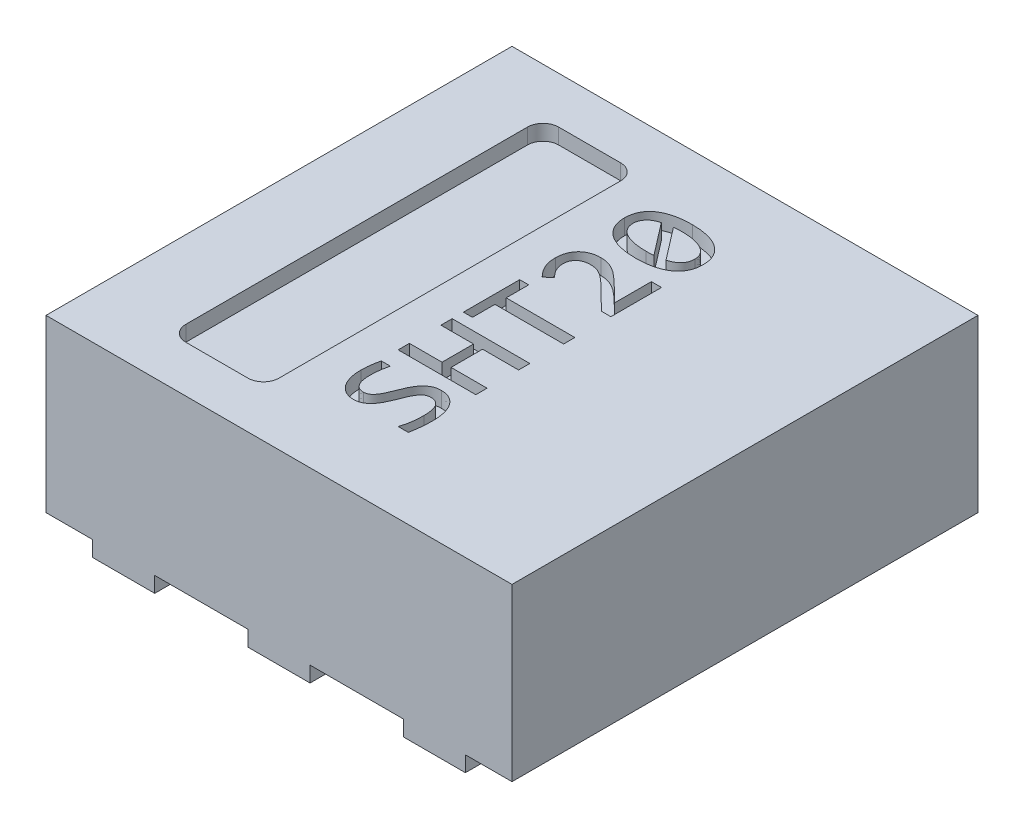
from build123d import *

# Parameters (mm, degrees)
SKETCH_1_W          = 3
SKETCH_1_H          = 3
EXTRUDE_1_DEPTH     = 1.1
CUT_EXTRUDE_1_DEPTH = 0.1
SKETCH_3_W          = 0.4
SKETCH_3_H          = 0.4
EXTRUDE_2_DEPTH     = 0.1
CUT_EXTRUDE_2_DEPTH = 0.1


with BuildPart() as part:
    # Эскиз1 → Бобышка-Вытянуть1 (new body)
    with BuildSketch(Plane(origin=(0, 0, 0), x_dir=(1, 0, 0), z_dir=(0, 1, 0))):
        Rectangle(SKETCH_1_W, SKETCH_1_H)
    extrude(amount=EXTRUDE_1_DEPTH)

    # Эскиз2 → Вырез-Вытянуть1 (cut)
    with BuildSketch(Plane(origin=(0, 1.1, 0), x_dir=(1, 0, 0), z_dir=(0, 1, 0))):
        with BuildLine():
            Line((-0.9, 1.2), (-0.5, 1.2))
            ThreePointArc((-0.5, 1.2), (-0.429289322, 1.170710678), (-0.4, 1.1))
            Line((-0.4, 1.1), (-0.4, -1.1))
            ThreePointArc((-0.4, -1.1), (-0.429289322, -1.170710678), (-0.5, -1.2))
            Line((-0.5, -1.2), (-0.9, -1.2))
            ThreePointArc((-0.9, -1.2), (-0.970710678, -1.170710678), (-1, -1.1))
            Line((-1, -1.1), (-1, 1.1))
            ThreePointArc((-1, 1.1), (-0.970710678, 1.170710678), (-0.9, 1.2))
        make_face()
    extrude(amount=-CUT_EXTRUDE_1_DEPTH, mode=Mode.SUBTRACT)

    # Эскиз3 → Бобышка-Вытянуть2 (add)
    with BuildSketch(Plane.XZ):
        Polygon((1.2, -0.75), (-1.2, -0.75), (-1.2, 0.35), (-0.8, 0.75), (1.2, 0.75), align=None)
        with Locations((1, -1.3)):
            Rectangle(SKETCH_3_W, SKETCH_3_H)
        with Locations((0, -1.3)):
            Rectangle(SKETCH_3_W, SKETCH_3_H)
        with Locations((-1, -1.3)):
            Rectangle(SKETCH_3_W, SKETCH_3_H)
        with Locations((1, 1.3)):
            Rectangle(SKETCH_3_W, SKETCH_3_H)
        with Locations((0, 1.3)):
            Rectangle(SKETCH_3_W, SKETCH_3_H)
        with Locations((-1, 1.3)):
            Rectangle(SKETCH_3_W, SKETCH_3_H)
    extrude(amount=EXTRUDE_2_DEPTH)

    # Эскиз4 → Вырез-Вытянуть2 (cut)
    with BuildSketch(Plane(origin=(0, 1.1, 0), x_dir=(1, 0, 0), z_dir=(0, 1, 0))):
        with BuildLine():
            add(Edge.make_bspline(
                [(0.190506672, -0.645766867), (0.196291492, -0.645933457), (0.20755118, -0.646257709), (0.223893074, -0.648989474), (0.239052887, -0.653672633), (0.253140322, -0.660057197), (0.266025063, -0.668126326), (0.277864823, -0.677647531), (0.288511242, -0.688642293), (0.297922262, -0.701146172), (0.306372605, -0.714860059), (0.313446819, -0.730071994), (0.31956784, -0.746495785), (0.324517643, -0.764190834), (0.328295084, -0.783011345), (0.33117149, -0.802809666), (0.332705802, -0.823580535), (0.332938038, -0.837718111), (0.333056491, -0.844929005)],
                knots=[0, 0, 0, 0, 1.7347e-05, 3.3765e-05, 4.9523e-05, 6.4825e-05, 8.0031e-05, 9.5009e-05, 0.000110302, 0.000125814, 0.000141874, 0.000158536, 0.000176056, 0.000194408, 0.000213593, 0.000233609, 0.000254389, 0.000276023, 0.000276023, 0.000276023, 0.000276023], degree=3))
            add(Edge.make_bspline(
                [(0.333056491, -0.844929005), (0.332998648, -0.851573327), (0.332883221, -0.864831989), (0.331727024, -0.884528981), (0.330473184, -0.903829605), (0.328581794, -0.922388042), (0.326658131, -0.94011778), (0.324082097, -0.956700635), (0.32161067, -0.972059482), (0.319544225, -0.981749061), (0.318563737, -0.986346578)],
                knots=[0, 0, 0, 0, 1.993e-05, 3.9771e-05, 5.918e-05, 7.795e-05, 9.573e-05, 0.000112671, 0.000128288, 0.000142389, 0.000142389, 0.000142389, 0.000142389], degree=3))
            Line((0.318563737, -0.986346578), (0.253346346, -0.986346578))
            add(Edge.make_bspline(
                [(0.253346346, -0.986346578), (0.25503366, -0.981421988), (0.258481268, -0.971359811), (0.262524998, -0.955576348), (0.266322687, -0.939020013), (0.269495419, -0.921533481), (0.271992514, -0.902946391), (0.273748691, -0.883187828), (0.27493796, -0.862191417), (0.275035389, -0.847799112), (0.275085477, -0.84040002)],
                knots=[0, 0, 0, 0, 1.5611e-05, 3.1897e-05, 4.8845e-05, 6.6568e-05, 8.5191e-05, 0.000105087, 0.000126065, 0.000148259, 0.000148259, 0.000148259, 0.000148259], degree=3))
            add(Edge.make_bspline(
                [(0.275085477, -0.84040002), (0.275031059, -0.835113724), (0.274926389, -0.824945766), (0.273832092, -0.810294257), (0.272405406, -0.796840067), (0.269927368, -0.784612186), (0.267075136, -0.773487869), (0.263445537, -0.76343295), (0.259126217, -0.754463015), (0.254283683, -0.746422537), (0.248689894, -0.739529221), (0.242656931, -0.733494189), (0.235916222, -0.728601157), (0.228604834, -0.724760995), (0.220819494, -0.721761086), (0.212476972, -0.719773992), (0.203604597, -0.71849462), (0.197493494, -0.718320184), (0.19435631, -0.718230636)],
                knots=[0, 0, 0, 0, 1.5855e-05, 3.0497e-05, 4.4063e-05, 5.6409e-05, 6.7889e-05, 7.8491e-05, 8.8417e-05, 9.7719e-05, 0.000106578, 0.000114985, 0.000123251, 0.000131456, 0.000139699, 0.000148212, 0.000157131, 0.00016654, 0.00016654, 0.00016654, 0.00016654], degree=3))
            add(Edge.make_bspline(
                [(0.19435631, -0.718230636), (0.191096846, -0.718343064), (0.184728538, -0.718562724), (0.175592246, -0.720806407), (0.167119782, -0.724314391), (0.159563589, -0.729457264), (0.152463983, -0.735501066), (0.145958178, -0.742601016), (0.139668436, -0.750438917), (0.131752132, -0.762328705), (0.122494968, -0.779002331), (0.112991401, -0.801080587), (0.103877319, -0.824678698), (0.094071768, -0.848757066), (0.083806669, -0.872927174), (0.072639906, -0.896471069), (0.060320198, -0.918833584), (0.047650336, -0.935354783), (0.036578133, -0.947163355), (0.02758022, -0.955056226), (0.017762574, -0.96191825), (0.007392035, -0.968146492), (-0.003964964, -0.973084763), (-0.016266722, -0.97653706), (-0.029557991, -0.978784672), (-0.038763513, -0.978992579), (-0.043528654, -0.979100201)],
                knots=[0, 0, 0, 0, 9.761e-06, 1.9071e-05, 2.8051e-05, 3.7126e-05, 4.6362e-05, 5.5974e-05, 6.5965e-05, 7.6485e-05, 9.8788e-05, 0.000123068, 0.00014853, 0.000174686, 0.00020106, 0.000227293, 0.000252853, 0.000277491, 0.000289505, 0.000301381, 0.000313319, 0.000325398, 0.000337618, 0.000350341, 0.00036365, 0.000377932, 0.000377932, 0.000377932, 0.000377932], degree=3))
            add(Edge.make_bspline(
                [(-0.043528654, -0.979100201), (-0.047801662, -0.978970292), (-0.056358176, -0.978710155), (-0.069143663, -0.976561324), (-0.081817294, -0.973181604), (-0.094333665, -0.968424094), (-0.106400444, -0.962190167), (-0.117976783, -0.954611517), (-0.128624141, -0.945253826), (-0.138781786, -0.934644748), (-0.147983004, -0.922274593), (-0.15622054, -0.9083319), (-0.163445654, -0.892743026), (-0.169963097, -0.875659162), (-0.175149041, -0.85679107), (-0.178860956, -0.836221242), (-0.180956789, -0.813948923), (-0.181272773, -0.798549037), (-0.181436263, -0.790581179)],
                knots=[0, 0, 0, 0, 1.2812e-05, 2.5656e-05, 3.8784e-05, 5.2116e-05, 6.5738e-05, 7.9461e-05, 9.3511e-05, 0.000108167, 0.000123453, 0.000139647, 0.000156666, 0.00017494, 0.000194444, 0.000215275, 0.000237571, 0.000261475, 0.000261475, 0.000261475, 0.000261475], degree=3))
            add(Edge.make_bspline(
                [(-0.181436263, -0.790581179), (-0.18134857, -0.786126869), (-0.181166383, -0.776872789), (-0.180374349, -0.762595553), (-0.179013786, -0.747721147), (-0.177179421, -0.732589437), (-0.175059139, -0.71748423), (-0.172566537, -0.702654474), (-0.169904449, -0.68841863), (-0.167907502, -0.679201698), (-0.166943509, -0.674752375)],
                knots=[0, 0, 0, 0, 1.3365e-05, 2.7766e-05, 4.2886e-05, 5.8166e-05, 7.349e-05, 8.8642e-05, 0.000103276, 0.000116933, 0.000116933, 0.000116933, 0.000116933], degree=3))
            Line((-0.166943509, -0.674752375), (-0.108972494, -0.674752375))
            add(Edge.make_bspline(
                [(-0.108972494, -0.674752375), (-0.111152689, -0.684658093), (-0.115492688, -0.704376892), (-0.12009266, -0.734006771), (-0.122909142, -0.763163549), (-0.123282073, -0.782385344), (-0.123465248, -0.79182665)],
                knots=[0, 0, 0, 0, 3.0422e-05, 6.056e-05, 8.9898e-05, 0.000118219, 0.000118219, 0.000118219, 0.000118219], degree=3))
            add(Edge.make_bspline(
                [(-0.123465248, -0.79182665), (-0.123392542, -0.79658327), (-0.123251608, -0.805803463), (-0.122385106, -0.819151769), (-0.120798379, -0.831511289), (-0.118652336, -0.842894581), (-0.115996576, -0.853333103), (-0.112622548, -0.862794729), (-0.108504102, -0.871227333), (-0.103876768, -0.878772797), (-0.098638385, -0.885320338), (-0.093077165, -0.891076166), (-0.087029943, -0.895881655), (-0.080497798, -0.899760705), (-0.073567578, -0.902796371), (-0.066268263, -0.905153938), (-0.058475948, -0.906350493), (-0.05315614, -0.906539676), (-0.050435357, -0.906636433)],
                knots=[0, 0, 0, 0, 1.427e-05, 2.7662e-05, 4.0104e-05, 5.1629e-05, 6.2395e-05, 7.2387e-05, 8.1705e-05, 9.0502e-05, 9.8884e-05, 0.00010681, 0.000114467, 0.000121982, 0.000129535, 0.000137127, 0.000144926, 0.000153091, 0.000153091, 0.000153091, 0.000153091], degree=3))
            add(Edge.make_bspline(
                [(-0.050435357, -0.906636433), (-0.047175778, -0.906524768), (-0.040807246, -0.906306599), (-0.031638586, -0.904043866), (-0.023149523, -0.900562109), (-0.015439942, -0.895517847), (-0.008399772, -0.889358222), (-0.001651622, -0.882391449), (0.00469448, -0.874535987), (0.01280075, -0.862661446), (0.022087686, -0.845909498), (0.03158257, -0.823761921), (0.040865253, -0.800214709), (0.050640483, -0.776109783), (0.06088313, -0.751911991), (0.070392355, -0.73218363), (0.07855915, -0.716873854), (0.085404979, -0.706144883), (0.092624812, -0.695957172), (0.100602687, -0.686591621), (0.109034888, -0.677795046), (0.118300976, -0.669979495), (0.128120737, -0.662900327), (0.138777492, -0.656862946), (0.150234411, -0.651743344), (0.162800481, -0.64834273), (0.176309386, -0.646079689), (0.185665684, -0.645873533), (0.190506672, -0.645766867)],
                knots=[0, 0, 0, 0, 9.761e-06, 1.9071e-05, 2.8155e-05, 3.7169e-05, 4.6564e-05, 5.6173e-05, 6.6234e-05, 7.6818e-05, 9.9275e-05, 0.000123555, 0.000149059, 0.000175215, 0.000201589, 0.000227871, 0.000240893, 0.000253615, 0.000266027, 0.00027832, 0.000290491, 0.000302538, 0.000314634, 0.000326754, 0.000339228, 0.000352168, 0.0003657, 0.000380209, 0.000380209, 0.000380209, 0.000380209], degree=3))
        make_face()
        Polygon((0.325810114, -0.210984259), (0.325810114, -0.283448027), (0.093926056, -0.283448027), (0.093926056, -0.486346578), (0.325810114, -0.486346578), (0.325810114, -0.558810346), (-0.174189886, -0.558810346), (-0.174189886, -0.486346578), (0.035955042, -0.486346578), (0.035955042, -0.283448027), (-0.174189886, -0.283448027), (-0.174189886, -0.210984259), align=None)
        Polygon((-0.116218871, 0.22379835), (-0.116218871, 0.078870814), (0.325810114, 0.078870814), (0.325810114, 0.006407046), (-0.116218871, 0.006407046), (-0.116218871, -0.138520491), (-0.174189886, -0.138520491), (-0.174189886, 0.22379835), align=None)
        with BuildLine():
            Line((0.325810114, 0.636841828), (0.325810114, 0.310754872))
            Line((0.325810114, 0.310754872), (0.264329136, 0.310754872))
            Line((0.264329136, 0.310754872), (0.137064643, 0.436660669))
            add(Edge.make_bspline(
                [(0.137064643, 0.436660669), (0.132048273, 0.441570121), (0.122434464, 0.450979025), (0.108587052, 0.464432663), (0.09549962, 0.476178409), (0.083458948, 0.486679149), (0.072199311, 0.49598389), (0.061409762, 0.503982309), (0.051257472, 0.511103316), (0.041442476, 0.516971297), (0.032121498, 0.522069564), (0.0230103, 0.526115165), (0.014211987, 0.529516946), (0.002529255, 0.53245972), (-0.012476403, 0.534945987), (-0.024683584, 0.535240902), (-0.030960719, 0.535392553)],
                knots=[0, 0, 0, 0, 2.1058e-05, 4.0357e-05, 5.7912e-05, 7.3804e-05, 8.8287e-05, 0.000101716, 0.00011409, 0.000125469, 0.000136005, 0.000145938, 0.00015536, 0.000164258, 0.000182035, 0.000200852, 0.000200852, 0.000200852, 0.000200852], degree=3))
            add(Edge.make_bspline(
                [(-0.030960719, 0.535392553), (-0.03701848, 0.535154055), (-0.048980379, 0.534683108), (-0.063531801, 0.531537569), (-0.074547973, 0.528011307), (-0.082143194, 0.524404618), (-0.089336952, 0.520339597), (-0.096036694, 0.515622655), (-0.102054025, 0.510095898), (-0.107629402, 0.504001059), (-0.11215838, 0.49685607), (-0.116364733, 0.489186897), (-0.119461288, 0.480578093), (-0.121895105, 0.47127184), (-0.123216732, 0.461117052), (-0.123380565, 0.454100721), (-0.123465248, 0.450474075)],
                knots=[0, 0, 0, 0, 1.8159e-05, 3.5857e-05, 4.445e-05, 5.2809e-05, 6.1024e-05, 6.9224e-05, 7.7321e-05, 8.5501e-05, 9.3917e-05, 0.000102629, 0.000111693, 0.000121277, 0.000131445, 0.000142324, 0.000142324, 0.000142324, 0.000142324], degree=3))
            add(Edge.make_bspline(
                [(-0.123465248, 0.450474075), (-0.123284107, 0.44540627), (-0.122926147, 0.435391628), (-0.120297004, 0.420722925), (-0.115829036, 0.406774419), (-0.109656958, 0.393584072), (-0.101947236, 0.381117115), (-0.093224305, 0.36916678), (-0.083580126, 0.357584065), (-0.076387486, 0.350477011), (-0.07274061, 0.346873531)],
                knots=[0, 0, 0, 0, 1.5199e-05, 3.0035e-05, 4.4537e-05, 5.9025e-05, 7.3608e-05, 8.8442e-05, 0.000103389, 0.000118761, 0.000118761, 0.000118761, 0.000118761], degree=3))
            Line((-0.07274061, 0.346873531), (-0.116332096, 0.310754872))
            add(Edge.make_bspline(
                [(-0.116332096, 0.310754872), (-0.121109258, 0.315496522), (-0.130633781, 0.324950243), (-0.143158482, 0.340698468), (-0.154299096, 0.357397819), (-0.164058373, 0.375149794), (-0.171984712, 0.394264173), (-0.177479746, 0.414932625), (-0.180804313, 0.43704328), (-0.181221788, 0.452273689), (-0.181436263, 0.460098169)],
                knots=[0, 0, 0, 0, 2.0178e-05, 4.023e-05, 6.0234e-05, 8.0349e-05, 0.000100912, 0.000122144, 0.000144353, 0.000167818, 0.000167818, 0.000167818, 0.000167818], degree=3))
            add(Edge.make_bspline(
                [(-0.181436263, 0.460098169), (-0.181354737, 0.46546441), (-0.181195142, 0.475969467), (-0.1791438, 0.49133441), (-0.176143021, 0.506009061), (-0.171886576, 0.51995704), (-0.166235717, 0.533006938), (-0.159786631, 0.54528801), (-0.151927174, 0.556490616), (-0.143119572, 0.566792811), (-0.133240268, 0.576184779), (-0.12216011, 0.584270103), (-0.110236756, 0.591554013), (-0.097104692, 0.597352986), (-0.083121811, 0.602187404), (-0.068171092, 0.605357383), (-0.05246027, 0.607504813), (-0.041686995, 0.607737263), (-0.036169052, 0.607856321)],
                knots=[0, 0, 0, 0, 1.6088e-05, 3.1494e-05, 4.6416e-05, 6.0992e-05, 7.5146e-05, 8.9026e-05, 0.000102532, 0.000116102, 0.000129638, 0.000143316, 0.000157181, 0.000171471, 0.000186294, 0.000201485, 0.000217243, 0.000233788, 0.000233788, 0.000233788, 0.000233788], degree=3))
            add(Edge.make_bspline(
                [(-0.036169052, 0.607856321), (-0.031486339, 0.607768086), (-0.022251734, 0.607594081), (-0.008689379, 0.606258983), (0.004320696, 0.603840308), (0.016882838, 0.600535208), (0.029192838, 0.596274505), (0.041451312, 0.591220185), (0.053573556, 0.58501721), (0.065767751, 0.577985275), (0.077967639, 0.569853045), (0.090503758, 0.560967357), (0.103001295, 0.550758607), (0.115979566, 0.539810944), (0.12918276, 0.527664947), (0.14319667, 0.514813498), (0.157641509, 0.500716574), (0.167455454, 0.490941758), (0.172503955, 0.485913386)],
                knots=[0, 0, 0, 0, 1.4047e-05, 2.7702e-05, 4.0827e-05, 5.3707e-05, 6.6633e-05, 7.988e-05, 9.3451e-05, 0.000107453, 0.000122087, 0.00013742, 0.000153529, 0.000170477, 0.000188353, 0.000207341, 0.000227519, 0.000248896, 0.000248896, 0.000248896, 0.000248896], degree=3))
            Line((0.172503955, 0.485913386), (0.260592723, 0.397711393))
            Line((0.260592723, 0.397711393), (0.260592723, 0.636841828))
            Line((0.260592723, 0.636841828), (0.325810114, 0.636841828))
        make_face()
        with BuildLine():
            add(Edge.make_bspline(
                [(0.076036564, 1.08611719), (0.085401821, 1.086013896), (0.103746126, 1.085811567), (0.130579673, 1.083434075), (0.156191183, 1.079881938), (0.180485482, 1.074811288), (0.20337435, 1.068369172), (0.224564319, 1.06013958), (0.244126089, 1.050553188), (0.262002621, 1.03941123), (0.278138205, 1.026893027), (0.292362457, 1.012794431), (0.304631872, 0.997256812), (0.314895467, 0.980219235), (0.32319079, 0.961754767), (0.3288536, 0.941648191), (0.332496839, 0.920073604), (0.332866284, 0.905162071), (0.333056491, 0.897484944)],
                knots=[0, 0, 0, 0, 2.8088e-05, 5.5018e-05, 8.0749e-05, 0.00010562, 0.000129416, 0.000151998, 0.000173721, 0.000194676, 0.000215083, 0.000234859, 0.000254611, 0.00027432, 0.000294393, 0.00031514, 0.000336825, 0.000359838, 0.000359838, 0.000359838, 0.000359838], degree=3))
            add(Edge.make_bspline(
                [(0.333056491, 0.897484944), (0.332895386, 0.890832366), (0.332578062, 0.877728947), (0.329689074, 0.858552282), (0.324927139, 0.840286619), (0.318261298, 0.823005369), (0.309578398, 0.806818068), (0.299005574, 0.791700893), (0.286180643, 0.777952298), (0.271331418, 0.765455674), (0.254484377, 0.754159341), (0.235348081, 0.744453353), (0.214153242, 0.736021484), (0.190815558, 0.728829354), (0.165262985, 0.723414424), (0.137516505, 0.719305529), (0.107515078, 0.716983081), (0.086759079, 0.716698821), (0.076036564, 0.716551973)],
                knots=[0, 0, 0, 0, 1.9948e-05, 3.9291e-05, 5.8021e-05, 7.6482e-05, 9.4718e-05, 0.000113001, 0.000131669, 0.00015095, 0.000171111, 0.000192379, 0.000215192, 0.000239474, 0.000265547, 0.000293473, 0.000323571, 0.000355737, 0.000355737, 0.000355737, 0.000355737], degree=3))
            add(Edge.make_bspline(
                [(0.076036564, 0.716551973), (0.066673173, 0.71672094), (0.048298949, 0.717052512), (0.021364087, 0.719155768), (-0.00434448, 0.722924323), (-0.028726043, 0.728051971), (-0.051655146, 0.734680712), (-0.072916609, 0.742881954), (-0.092583886, 0.752319409), (-0.110515566, 0.763327603), (-0.126522285, 0.775933063), (-0.140743304, 0.789984098), (-0.153044075, 0.805543988), (-0.163273806, 0.822681836), (-0.171550493, 0.841224993), (-0.177221754, 0.861324253), (-0.1808721, 0.882783721), (-0.181244812, 0.89758254), (-0.181436263, 0.905184219)],
                knots=[0, 0, 0, 0, 2.8091e-05, 5.5124e-05, 8.0984e-05, 0.000105989, 0.000129816, 0.000152504, 0.000174279, 0.000195175, 0.000215493, 0.000235268, 0.00025502, 0.000274826, 0.000295002, 0.00031575, 0.000337323, 0.00036011, 0.00036011, 0.00036011, 0.00036011], degree=3))
            add(Edge.make_bspline(
                [(-0.181436263, 0.905184219), (-0.181273423, 0.911836299), (-0.180952682, 0.924938737), (-0.178093868, 0.944086315), (-0.17326051, 0.962278911), (-0.166744736, 0.979590876), (-0.15814215, 0.995848642), (-0.147336523, 1.010868116), (-0.134453369, 1.024568938), (-0.119591025, 1.037147171), (-0.102596624, 1.048364132), (-0.083473378, 1.058244161), (-0.06216306, 1.066503029), (-0.038845306, 1.07370449), (-0.013283034, 1.079305504), (0.014485622, 1.083334284), (0.044518865, 1.085698914), (0.065275856, 1.085974384), (0.076036564, 1.08611719)],
                knots=[0, 0, 0, 0, 1.9948e-05, 3.9291e-05, 5.7912e-05, 7.6332e-05, 9.4668e-05, 0.000112924, 0.000131669, 0.000150951, 0.000171205, 0.000192626, 0.000215397, 0.000239679, 0.000265776, 0.000293814, 0.0003238, 0.000356079, 0.000356079, 0.000356079, 0.000356079], degree=3))
        make_face()
        with BuildLine():
            add(Edge.make_bspline(
                [(0.079886201, 1.013653422), (0.075544045, 1.013626604), (0.066852353, 1.013572922), (0.053955239, 1.012622791), (0.041227233, 1.0117996), (0.03285858, 1.010995233), (0.028708665, 1.010596357)],
                knots=[0, 0, 0, 0, 1.3023e-05, 2.6068e-05, 3.8781e-05, 5.1287e-05, 5.1287e-05, 5.1287e-05, 5.1287e-05], degree=3))
            Line((0.028708665, 1.010596357), (0.188128955, 0.803168821))
            add(Edge.make_bspline(
                [(0.188128955, 0.803168821), (0.194288622, 0.805200044), (0.206305198, 0.809162652), (0.223170883, 0.816986514), (0.238275648, 0.826366744), (0.250986303, 0.837891255), (0.261524384, 0.850957242), (0.267847917, 0.863439202), (0.271643287, 0.874103052), (0.273696581, 0.8827534), (0.274774469, 0.891947425), (0.274980375, 0.898237257), (0.275085477, 0.901447806)],
                knots=[0, 0, 0, 0, 1.9445e-05, 3.7934e-05, 5.5649e-05, 7.2565e-05, 8.9169e-05, 0.000105728, 0.000114251, 0.000123094, 0.000132335, 0.00014197, 0.00014197, 0.00014197, 0.00014197], degree=3))
            add(Edge.make_bspline(
                [(0.275085477, 0.901447806), (0.274942409, 0.905612598), (0.274660355, 0.913823419), (0.272142393, 0.925796095), (0.268381219, 0.937263412), (0.26265947, 0.947954394), (0.255699626, 0.958088583), (0.247020317, 0.967310178), (0.237002332, 0.975880157), (0.225362381, 0.983543483), (0.212267766, 0.990442137), (0.197696988, 0.996579089), (0.181582791, 1.001739514), (0.164005428, 1.005959956), (0.145048964, 1.009526447), (0.124624225, 1.011946417), (0.10274256, 1.013441183), (0.087663543, 1.013581203), (0.079886201, 1.013653422)],
                knots=[0, 0, 0, 0, 1.248e-05, 2.4604e-05, 3.6563e-05, 4.8565e-05, 6.0846e-05, 7.3345e-05, 8.6437e-05, 0.000100317, 0.000115056, 0.000130786, 0.000147686, 0.000165756, 0.000184987, 0.000205519, 0.000227421, 0.00025075, 0.00025075, 0.00025075, 0.00025075], degree=3))
        make_face(mode=Mode.SUBTRACT)
        with BuildLine():
            add(Edge.make_bspline(
                [(0.075243991, 0.789015741), (0.079282358, 0.789011032), (0.087359267, 0.789001615), (0.099401554, 0.789071826), (0.111265366, 0.789471279), (0.11906413, 0.79015189), (0.122911564, 0.790487662)],
                knots=[0, 0, 0, 0, 1.2115e-05, 2.4231e-05, 3.6128e-05, 4.7712e-05, 4.7712e-05, 4.7712e-05, 4.7712e-05], degree=3))
            Line((0.122911564, 0.790487662), (-0.036508726, 0.998028422))
            add(Edge.make_bspline(
                [(-0.036508726, 0.998028422), (-0.042714255, 0.996057043), (-0.054814511, 0.992213018), (-0.071575162, 0.984239285), (-0.086568621, 0.974846707), (-0.099340303, 0.963628393), (-0.109781303, 0.950610492), (-0.116222953, 0.938346281), (-0.120001945, 0.927807036), (-0.122080663, 0.919353402), (-0.123148483, 0.910419868), (-0.123358591, 0.904318552), (-0.123465248, 0.901221357)],
                knots=[0, 0, 0, 0, 1.9514e-05, 3.8051e-05, 5.5515e-05, 7.244e-05, 8.8797e-05, 0.000105308, 0.000113724, 0.000122347, 0.000131363, 0.000140658, 0.000140658, 0.000140658, 0.000140658], degree=3))
            add(Edge.make_bspline(
                [(-0.123465248, 0.901221357), (-0.123317161, 0.897058396), (-0.12302521, 0.888851185), (-0.120584199, 0.876875082), (-0.116554581, 0.865495111), (-0.110980853, 0.854701173), (-0.103840185, 0.844541128), (-0.094899626, 0.835364124), (-0.084735247, 0.826662503), (-0.072798424, 0.818997706), (-0.059419799, 0.812091819), (-0.04448968, 0.806136378), (-0.028134959, 0.800959906), (-0.010340968, 0.796512304), (0.009004745, 0.793189756), (0.029787624, 0.790715398), (0.052048991, 0.789231291), (0.067353696, 0.789089065), (0.075243991, 0.789015741)],
                knots=[0, 0, 0, 0, 1.248e-05, 2.4604e-05, 3.6493e-05, 4.8596e-05, 6.0942e-05, 7.3596e-05, 8.6933e-05, 0.000101002, 0.000116043, 0.000132043, 0.000149159, 0.000167475, 0.000187021, 0.000208003, 0.000230244, 0.000253912, 0.000253912, 0.000253912, 0.000253912], degree=3))
        make_face(mode=Mode.SUBTRACT)
    extrude(amount=-CUT_EXTRUDE_2_DEPTH, mode=Mode.SUBTRACT)


solid = part.part
